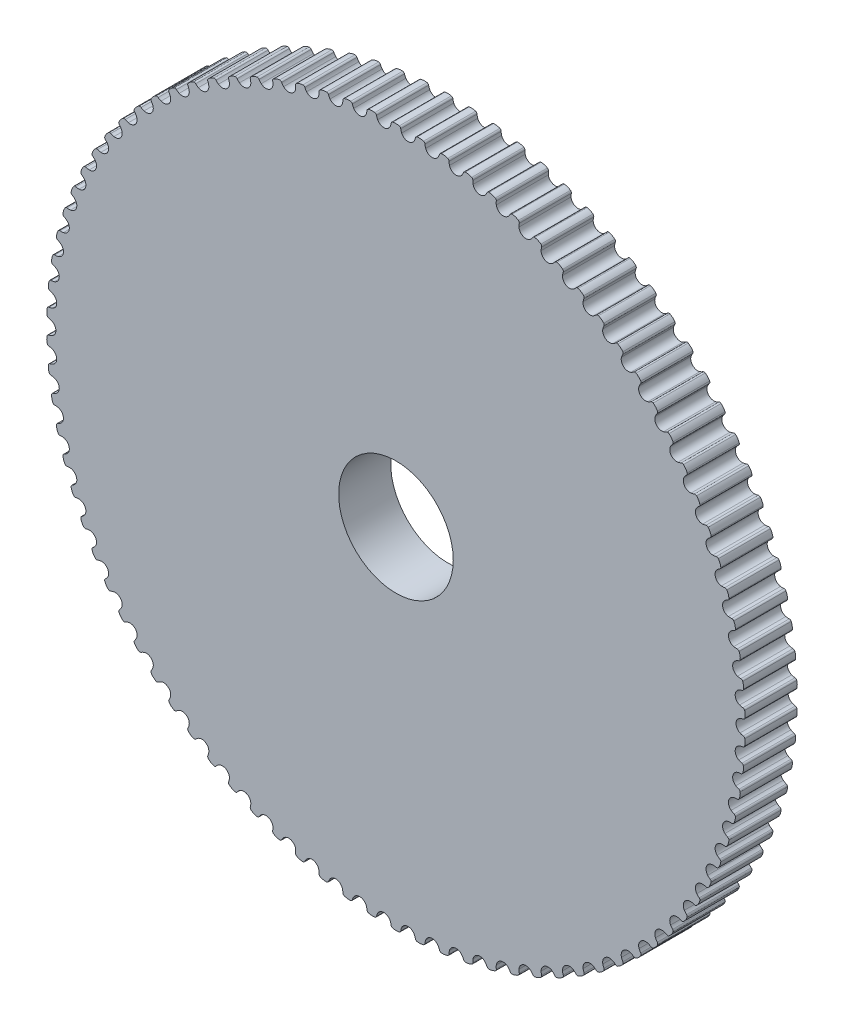
from build123d import *

# Parameters (mm, degrees)
SKETCH1_R               = 42.97183601
BOSS_EXTRUDE1_DEPTH     = 3.175
CUT_EXTRUDE1_START      = -7.35
CUT_EXTRUDE1_DEPTH      = 8.35
CIRPATTERN1_COUNT       = 90
F_3_8_CLEARANCE_HOLE1_D = 13.97


with BuildPart() as part:
    # Sketch1 → Boss-Extrude1 (new body, symmetric)
    with BuildSketch(Plane.XY):
        Circle(SKETCH1_R)
    extrude(amount=BOSS_EXTRUDE1_DEPTH, both=True)

    # Sketch3 → Cut-Extrude1 (cut)
    with BuildSketch(Plane.XY.offset(3.175).offset(CUT_EXTRUDE1_START)):
        with BuildLine():
            Line((0, 42.59083601), (0, 42.97183601))
            ThreePointArc((0, 42.97183601), (1.499695449, 42.945658728), (2.99756375, 42.867158777))
            Line((2.99756375, 42.867158777), (2.970986534, 42.487086874))
            ThreePointArc((2.970986534, 42.487086874), (2.770269257, 42.488861064), (2.57082678, 42.466205571))
            ThreePointArc((2.57082678, 42.466205571), (2.440332428, 42.399692369), (2.369492505, 42.271495304))
            ThreePointArc((2.369492505, 42.271495304), (2.313079512, 42.072121107), (2.230075804, 41.88227148))
            ThreePointArc((2.230075804, 41.88227148), (1.446613315, 41.425585281), (0.696916119, 41.935810596))
            ThreePointArc((0.696916119, 41.935810596), (0.627357844, 42.130987805), (0.584989912, 42.333811508))
            ThreePointArc((0.584989912, 42.333811508), (0.523265126, 42.466637834), (0.397728378, 42.542091839))
            ThreePointArc((0.397728378, 42.542091839), (0.200352101, 42.578604549), (0, 42.59083601))
        make_face()
    cut_extrude1 = extrude(amount=CUT_EXTRUDE1_DEPTH, mode=Mode.SUBTRACT)

    # CirPattern1: Cut-Extrude1 ×90 about axis
    cirpattern1_axis = Axis((0, 0, 3.175), (0, 0, -1))
    for i in range(1, CIRPATTERN1_COUNT):
        add(cut_extrude1.rotate(cirpattern1_axis, i * 360 / CIRPATTERN1_COUNT), mode=Mode.SUBTRACT)

    # 3/8 Clearance Hole1 (through all)
    with Locations(Plane.XY.offset(3.175)):
        with Locations((0, 0)):
            Hole(F_3_8_CLEARANCE_HOLE1_D / 2)


solid = part.part
